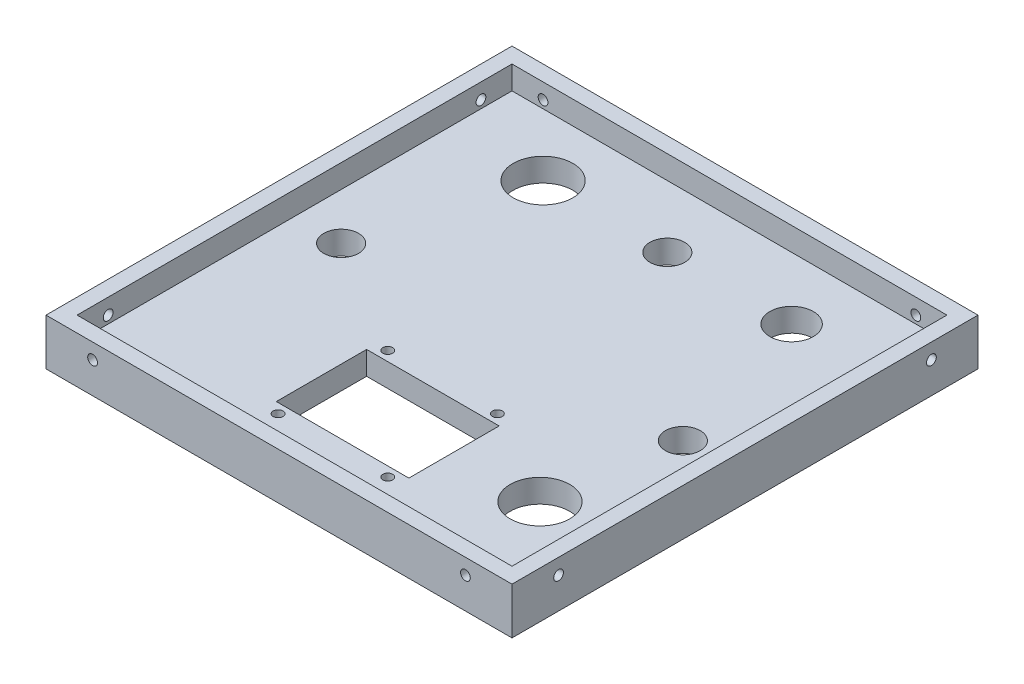
from build123d import *

# Parameters (mm, degrees)
SKETCH1_W           = 101.6
SKETCH1_H           = 101.6
BOSS_EXTRUDE1_DEPTH = 3.175
SKETCH2_W           = 101.6
SKETCH2_H           = 101.6
SKETCH2_W_2         = 88.9
SKETCH2_H_2         = 88.9
BOSS_EXTRUDE2_DEPTH = 6.35
SKETCH3_R           = 0.99949
CUT_EXTRUDE1_DEPTH  = 6.35
CIRPATTERN1_COUNT   = 4
SKETCH8_W           = 88.9
SKETCH8_H           = 88.9
BOSS_EXTRUDE3_DEPTH = 1.5875
SKETCH4_W           = 101.6
SKETCH4_H           = 101.6
SKETCH4_W_2         = 95.25
SKETCH4_H_2         = 95.25
CUT_EXTRUDE2_DEPTH  = 10.525
SKETCH6_R           = 3.556
SKETCH6_R_2         = 6.096
SKETCH6_R_3         = 4.445
INPUTS_DEPTH        = 10.525
SKETCH5_R           = 0.99949
SKETCH5_W           = 27.093418
SKETCH5_H           = 18.457418
SCREEN_DEPTH        = 10.525
SKETCH7_R           = 3.556
CUT_EXTRUDE5_DEPTH  = 10.525


with BuildPart() as part:
    # Sketch1 → Boss-Extrude1 (new body)
    with BuildSketch(Plane(origin=(0, 0, 0), x_dir=(1, 0, 0), z_dir=(0, 1, 0))):
        Rectangle(SKETCH1_W, SKETCH1_H)
    extrude(amount=BOSS_EXTRUDE1_DEPTH)

    # Sketch2 → Boss-Extrude2 (add)
    with BuildSketch(Plane(origin=(0, 3.175, 0), x_dir=(1, 0, 0), z_dir=(0, 1, 0))):
        Rectangle(SKETCH2_W, SKETCH2_H)
        Rectangle(SKETCH2_W_2, SKETCH2_H_2, mode=Mode.SUBTRACT)
    extrude(amount=BOSS_EXTRUDE2_DEPTH)

    # Sketch3 → Cut-Extrude1 (cut)
    with BuildSketch(Plane.XY.offset(50.8)):
        with Locations((-38.1, 6.35)):
            Circle(SKETCH3_R)
        with Locations((38.1, 6.35)):
            Circle(SKETCH3_R)
    cut_extrude1 = extrude(amount=-CUT_EXTRUDE1_DEPTH, mode=Mode.SUBTRACT)

    # CirPattern1: Cut-Extrude1 ×4 about axis
    cirpattern1_axis = Axis((0, 10.00125, 0), (0, -1, 0))
    for i in range(1, CIRPATTERN1_COUNT):
        add(cut_extrude1.rotate(cirpattern1_axis, i * 360 / CIRPATTERN1_COUNT), mode=Mode.SUBTRACT)

    # Sketch8 → Boss-Extrude3 (add)
    with BuildSketch(Plane(origin=(0, 3.175, 0), x_dir=(1, 0, 0), z_dir=(0, 1, 0))):
        Rectangle(SKETCH8_W, SKETCH8_H)
    extrude(amount=BOSS_EXTRUDE3_DEPTH)

    # Sketch4 → Cut-Extrude2 (cut, through all)
    with BuildSketch(Plane(origin=(0, 0, 0), x_dir=(1, 0, 0), z_dir=(0, 1, 0))):
        Rectangle(SKETCH4_W, SKETCH4_H)
        Rectangle(SKETCH4_W_2, SKETCH4_H_2, mode=Mode.SUBTRACT)
    extrude(amount=CUT_EXTRUDE2_DEPTH, mode=Mode.SUBTRACT)

    # Sketch6 → Inputs (cut, through all)
    with BuildSketch(Plane.XZ):
        with Locations((0, -31.75)):
            Circle(SKETCH6_R)
        with Locations((-25.4, -31.75)):
            Circle(SKETCH6_R_2)
        with Locations((25.4, -31.75)):
            Circle(SKETCH6_R_3)
        with Locations((31.115, 25.4)):
            Circle(SKETCH6_R_2)
    extrude(amount=-INPUTS_DEPTH, mode=Mode.SUBTRACT)

    # Sketch5 → Screen (cut, through all)
    with BuildSketch(Plane.XZ):
        with Locations((-11.205633292, 14.194366708)):
            Circle(SKETCH5_R)
        with Locations((11.205633292, 14.194366708)):
            Circle(SKETCH5_R)
        with Locations((11.205633292, 36.605633292)):
            Circle(SKETCH5_R)
        with Locations((-11.205633292, 36.605633292)):
            Circle(SKETCH5_R)
        with Locations((0, 25.4)):
            Rectangle(SKETCH5_W, SKETCH5_H)
    extrude(amount=-SCREEN_DEPTH, mode=Mode.SUBTRACT)

    # Sketch7 → Cut-Extrude5 (cut, through all)
    with BuildSketch(Plane.XZ):
        with Locations((-34.925, 0)):
            Circle(SKETCH7_R)
        with Locations((34.925, 0)):
            Circle(SKETCH7_R)
    extrude(amount=-CUT_EXTRUDE5_DEPTH, mode=Mode.SUBTRACT)


solid = part.part
